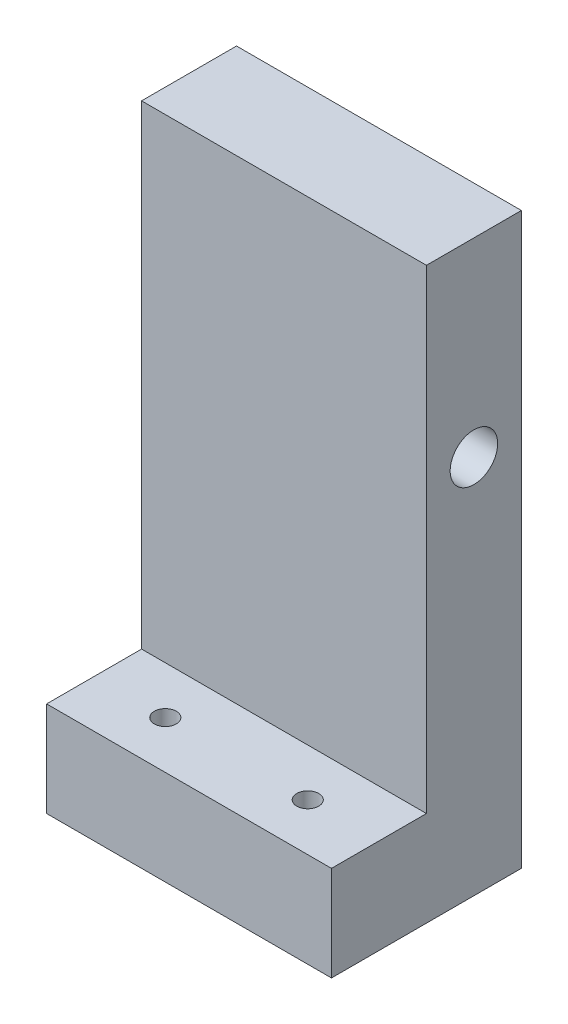
from build123d import *

# Parameters (mm, degrees)
BOSS_EXTRUDE1_DEPTH = 38.1
SKETCH2_R           = 3.175
CUT_EXTRUDE1_DEPTH  = 39.1
SKETCH3_R           = 1.4732
CUT_EXTRUDE2_DEPTH  = 13.7


with BuildPart() as part:
    # Sketch1 → Boss-Extrude1 (new body)
    with BuildSketch(Plane(origin=(0, 0, 0), x_dir=(0, 0, -1), z_dir=(1, 0, 0))):
        Polygon((0, 0), (0, 12.7), (12.7, 12.7), (12.7, 76.2), (25.4, 76.2), (25.4, 0), align=None)
    extrude(amount=BOSS_EXTRUDE1_DEPTH)

    # Sketch2 → Cut-Extrude1 (cut, through all)
    with BuildSketch(Plane(origin=(38.1, 0, 0), x_dir=(0, 0, -1), z_dir=(1, 0, 0))):
        with Locations((19.05, 50.8)):
            Circle(SKETCH2_R)
    extrude(amount=-CUT_EXTRUDE1_DEPTH, mode=Mode.SUBTRACT)

    # Sketch3 → Cut-Extrude2 (cut, through all)
    with BuildSketch(Plane(origin=(0, 12.7, 0), x_dir=(1, 0, 0), z_dir=(0, 1, 0))):
        with Locations((9.525, 6.35)):
            Circle(SKETCH3_R)
        with Locations((28.575, 6.35)):
            Circle(SKETCH3_R)
    extrude(amount=-CUT_EXTRUDE2_DEPTH, mode=Mode.SUBTRACT)


solid = part.part
